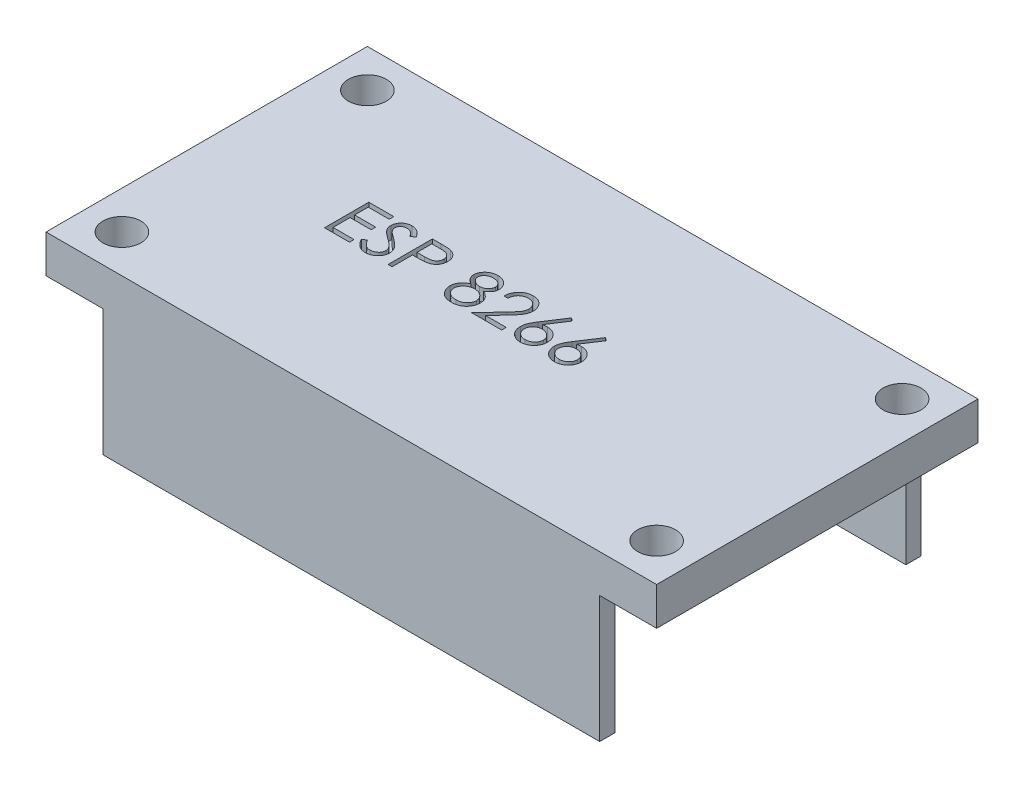
from build123d import *

# Parameters (mm, degrees)
SKETCH1_W           = 48.26
SKETCH1_H           = 25.4
BOSS_EXTRUDE1_DEPTH = 13
CUT_EXTRUDE1_DEPTH  = 10
CUT_EXTRUDE2_DEPTH  = 1
SKETCH4_R           = 1.5
CUT_EXTRUDE3_DEPTH  = 30


with BuildPart() as part:
    # Sketch1 → Boss-Extrude1 (new body)
    with BuildSketch(Plane(origin=(0, 0, 0), x_dir=(1, 0, 0), z_dir=(0, 1, 0))):
        with Locations((24.13, 12.7)):
            Rectangle(SKETCH1_W, SKETCH1_H)
    extrude(amount=BOSS_EXTRUDE1_DEPTH)

    # Sketch2 → Cut-Extrude1 (cut)
    with BuildSketch(Plane.XZ):
        Polygon((0, -1.2), (0, -24.2), (0, -25.4), (4.5, -25.4), (4.5, -24.2), (43.76, -24.2), (43.76, -25.4), (48.26, -25.4), (48.26, -24.2), (48.26, -1.2), (48.26, 0), (43.76, 0), (43.76, -1.2), (4.5, -1.2), (4.5, 0), (0, 0), align=None)
    extrude(amount=-CUT_EXTRUDE1_DEPTH, mode=Mode.SUBTRACT)

    # Sketch3 → Cut-Extrude2 (cut)
    with BuildSketch(Plane(origin=(0, 13, 0), x_dir=(1, 0, 0), z_dir=(0, 1, 0))):
        Polygon((10.717978937, 14.794873537), (12.692337911, 14.794873537), (12.692337911, 14.435899178), (11.032081501, 14.435899178), (11.032081501, 13.358976101), (12.692337911, 13.358976101), (12.692337911, 13.000001742), (11.032081501, 13.000001742), (11.032081501, 11.653847896), (12.692337911, 11.653847896), (12.692337911, 11.294873537), (10.717978937, 11.294873537), align=None)
        with BuildLine():
            Line((12.96156868, 11.970053825), (13.257442078, 12.147437639))
            add(Edge.make_bspline(
                [(13.257442078, 12.147437639), (13.284960315, 12.101373254), (13.337684196, 12.01311567), (13.425635555, 11.89385763), (13.516768466, 11.792495473), (13.6117578, 11.709618866), (13.710023748, 11.644369979), (13.812207801, 11.598167747), (13.917965612, 11.569351772), (13.989939434, 11.565851685), (14.025871565, 11.564104306)],
                knots=[0, 0, 0, 0, 0.000160901, 0.00030828, 0.000443778, 0.00056903, 0.000685513, 0.000796284, 0.00090427, 0.001011928, 0.001011928, 0.001011928, 0.001011928], degree=3))
            add(Edge.make_bspline(
                [(14.025871565, 11.564104306), (14.056558426, 11.564958978), (14.117395199, 11.566653369), (14.206957442, 11.582934171), (14.293939244, 11.6079463), (14.376547882, 11.643767231), (14.453643496, 11.687105717), (14.521250191, 11.739451894), (14.579696305, 11.7980581), (14.627505419, 11.863440755), (14.664185454, 11.933757903), (14.692377523, 12.005933855), (14.708022596, 12.081102423), (14.71037935, 12.131712886), (14.71156868, 12.157253344)],
                knots=[0, 0, 0, 0, 9.1978e-05, 0.000182347, 0.000272202, 0.000362975, 0.000451852, 0.000536835, 0.000618639, 0.000699414, 0.000778765, 0.000855983, 0.0009312, 0.001007828, 0.001007828, 0.001007828, 0.001007828], degree=3))
            add(Edge.make_bspline(
                [(14.71156868, 12.157253344), (14.71009437, 12.186394194), (14.707097311, 12.245633283), (14.681765831, 12.333032936), (14.641916585, 12.419525506), (14.605153941, 12.473026772), (14.586067879, 12.500803024)],
                knots=[0, 0, 0, 0, 8.7281e-05, 0.000177429, 0.000270909, 0.000371844, 0.000371844, 0.000371844, 0.000371844], degree=3))
            add(Edge.make_bspline(
                [(14.586067879, 12.500803024), (14.570397265, 12.520849847), (14.537498771, 12.562935646), (14.480941258, 12.625580881), (14.414575144, 12.6901993), (14.340671589, 12.759258357), (14.2565385, 12.829546154), (14.164810986, 12.904414432), (14.063147127, 12.981016009), (13.99184763, 13.032388575), (13.955058264, 13.058895972)],
                knots=[0, 0, 0, 0, 7.6319e-05, 0.000160223, 0.000252933, 0.000354147, 0.000463581, 0.000581729, 0.000709336, 0.000845369, 0.000845369, 0.000845369, 0.000845369], degree=3))
            add(Edge.make_bspline(
                [(13.955058264, 13.058895972), (13.918234268, 13.08512456), (13.847829591, 13.135271622), (13.749371009, 13.209695906), (13.661326546, 13.277739776), (13.584087529, 13.340043788), (13.517687932, 13.396616393), (13.461604521, 13.446914332), (13.417265964, 13.492297893), (13.392610383, 13.521739234), (13.381540636, 13.534957671)],
                knots=[0, 0, 0, 0, 0.000135623, 0.000259301, 0.000370234, 0.000469439, 0.00055697, 0.000631911, 0.000695377, 0.00074709, 0.00074709, 0.00074709, 0.00074709], degree=3))
            add(Edge.make_bspline(
                [(13.381540636, 13.534957671), (13.36606809, 13.555558708), (13.335639254, 13.596073412), (13.295473248, 13.65939827), (13.261334085, 13.724221535), (13.234571753, 13.7907174), (13.212035534, 13.857952328), (13.196877604, 13.926803574), (13.187386207, 13.996962193), (13.18641422, 14.044175693), (13.185927655, 14.067810235)],
                knots=[0, 0, 0, 0, 7.727e-05, 0.000151962, 0.000224716, 0.000296717, 0.00036678, 0.0004372, 0.000507902, 0.000578771, 0.000578771, 0.000578771, 0.000578771], degree=3))
            add(Edge.make_bspline(
                [(13.185927655, 14.067810235), (13.187232864, 14.10484001), (13.189815384, 14.178108074), (13.211655901, 14.285138904), (13.246128795, 14.387325321), (13.294423683, 14.483655655), (13.356681036, 14.571621636), (13.42872701, 14.652235123), (13.514538496, 14.720003705), (13.608691119, 14.779215763), (13.711747491, 14.825561689), (13.819738395, 14.860522669), (13.932835467, 14.880331927), (14.009438601, 14.883174691), (14.048307462, 14.884617126)],
                knots=[0, 0, 0, 0, 0.000110999, 0.000219625, 0.000326272, 0.00043382, 0.000541574, 0.000648775, 0.000756959, 0.000868438, 0.000981703, 0.00109501, 0.001208203, 0.0013248, 0.0013248, 0.0013248, 0.0013248], degree=3))
            add(Edge.make_bspline(
                [(14.048307462, 14.884617126), (14.089551563, 14.883194575), (14.171572914, 14.880365574), (14.29222213, 14.855768042), (14.408382846, 14.815067371), (14.501826111, 14.768878713), (14.574958873, 14.722747297), (14.630731605, 14.680727473), (14.687249056, 14.632352364), (14.744967111, 14.577493118), (14.80290777, 14.515646367), (14.861931223, 14.447235678), (14.922175492, 14.372679122), (14.960931352, 14.319454621), (14.98079945, 14.29216921)],
                knots=[0, 0, 0, 0, 0.000123638, 0.000245877, 0.000367608, 0.000492088, 0.000557638, 0.000626769, 0.000701372, 0.00078072, 0.000865532, 0.000955497, 0.001051745, 0.001152989, 0.001152989, 0.001152989, 0.001152989], degree=3))
            Line((14.98079945, 14.29216921), (14.696845123, 14.076924819))
            add(Edge.make_bspline(
                [(14.696845123, 14.076924819), (14.67969919, 14.099013509), (14.646680133, 14.141551162), (14.596550646, 14.201122478), (14.549301998, 14.255538957), (14.502751599, 14.302804085), (14.459357967, 14.345506219), (14.417240925, 14.382065976), (14.377006574, 14.412841571), (14.326289663, 14.445685131), (14.262571945, 14.478241635), (14.182587408, 14.505790713), (14.099001133, 14.522345775), (14.042071502, 14.524534662), (14.013251373, 14.525642767)],
                knots=[0, 0, 0, 0, 8.3877e-05, 0.000161528, 0.000233552, 0.000299993, 0.000360485, 0.000416152, 0.000467195, 0.000512312, 0.000597287, 0.000681099, 0.000765389, 0.000851809, 0.000851809, 0.000851809, 0.000851809], degree=3))
            add(Edge.make_bspline(
                [(14.013251373, 14.525642767), (13.97709485, 14.524431067), (13.907370403, 14.522094418), (13.808380167, 14.496574433), (13.719286242, 14.456392573), (13.642733677, 14.400077595), (13.5789967, 14.333356602), (13.532891241, 14.256577747), (13.505141076, 14.171795344), (13.501754797, 14.112653688), (13.500030219, 14.082533793)],
                knots=[0, 0, 0, 0, 0.000108248, 0.000208746, 0.00030443, 0.000399793, 0.000492054, 0.00057947, 0.000666386, 0.000756591, 0.000756591, 0.000756591, 0.000756591], degree=3))
            add(Edge.make_bspline(
                [(13.500030219, 14.082533793), (13.500423345, 14.063782314), (13.501210242, 14.026248695), (13.512185039, 13.970797273), (13.526284368, 13.915485934), (13.548627, 13.860563351), (13.579472304, 13.805068992), (13.61997748, 13.748047254), (13.670990792, 13.688995546), (13.710067804, 13.650588172), (13.730699289, 13.630310235)],
                knots=[0, 0, 0, 0, 5.616e-05, 0.000112411, 0.000169046, 0.000227244, 0.000289691, 0.000359134, 0.000436702, 0.000523463, 0.000523463, 0.000523463, 0.000523463], degree=3))
            add(Edge.make_bspline(
                [(13.730699289, 13.630310235), (13.738360662, 13.623473209), (13.756562329, 13.607230001), (13.789838255, 13.580637721), (13.833781053, 13.547834948), (13.887243254, 13.507247632), (13.951210616, 13.46016617), (14.025690172, 13.407192557), (14.109851705, 13.346607098), (14.169573621, 13.304249558), (14.201152014, 13.281852703)],
                knots=[0, 0, 0, 0, 3.0802e-05, 7.3177e-05, 0.000127725, 0.000195314, 0.000274544, 0.000365991, 0.000469501, 0.000585644, 0.000585644, 0.000585644, 0.000585644], degree=3))
            add(Edge.make_bspline(
                [(14.201152014, 13.281852703), (14.239137927, 13.254211344), (14.312692383, 13.200687682), (14.417349963, 13.120272002), (14.512243771, 13.041624233), (14.597706975, 12.965246626), (14.674583883, 12.891718533), (14.742021604, 12.820155353), (14.800707284, 12.75106978), (14.863886503, 12.662497205), (14.928444322, 12.55371612), (14.98388583, 12.420437882), (15.018844177, 12.286641561), (15.023415693, 12.196714725), (15.025671244, 12.152345492)],
                knots=[0, 0, 0, 0, 0.000140932, 0.000272896, 0.000395881, 0.000510584, 0.000616697, 0.000714904, 0.000805482, 0.000888372, 0.001041088, 0.001183793, 0.001320341, 0.001453327, 0.001453327, 0.001453327, 0.001453327], degree=3))
            add(Edge.make_bspline(
                [(15.025671244, 12.152345492), (15.025014106, 12.120967127), (15.023712591, 12.058819743), (15.008751678, 11.967564666), (14.986832012, 11.878933797), (14.953794778, 11.794022684), (14.91347162, 11.711277921), (14.862305372, 11.632870021), (14.802997688, 11.557063622), (14.734963923, 11.485880131), (14.66051802, 11.420533935), (14.581834326, 11.362404874), (14.498784053, 11.31393655), (14.411817736, 11.274385708), (14.320915399, 11.243452191), (14.226107615, 11.221039321), (14.127238104, 11.207283611), (14.060037623, 11.205855849), (14.025871565, 11.205129947)],
                knots=[0, 0, 0, 0, 9.4044e-05, 0.000186263, 0.000276729, 0.000367488, 0.000459046, 0.000552398, 0.000647774, 0.000747454, 0.000847311, 0.000944634, 0.001040472, 0.001135227, 0.001230788, 0.001328063, 0.00142712, 0.00152957, 0.00152957, 0.00152957, 0.00152957], degree=3))
            add(Edge.make_bspline(
                [(14.025871565, 11.205129947), (13.999436222, 11.205641128), (13.946898462, 11.206657054), (13.86918898, 11.215638334), (13.793049391, 11.228345438), (13.719435109, 11.248519508), (13.647397697, 11.272996485), (13.577250463, 11.303134817), (13.508959409, 11.339252019), (13.442141826, 11.380547044), (13.376967651, 11.428604788), (13.314048183, 11.484578285), (13.251318998, 11.54692379), (13.190631602, 11.617334353), (13.130758457, 11.694672436), (13.072880048, 11.779661619), (13.01579833, 11.871838973), (12.979982862, 11.936704059), (12.96156868, 11.970053825)],
                knots=[0, 0, 0, 0, 7.9276e-05, 0.000157554, 0.000234438, 0.000310629, 0.000386236, 0.000462555, 0.000539392, 0.000617798, 0.000698008, 0.000781971, 0.000870217, 0.00096315, 0.001060616, 0.001163492, 0.001271478, 0.00138575, 0.00138575, 0.00138575, 0.00138575], degree=3))
        make_face()
        with BuildLine():
            Line((15.743619962, 14.794873537), (16.4300182, 14.794873537))
            add(Edge.make_bspline(
                [(16.4300182, 14.794873537), (16.477229106, 14.79482164), (16.567687299, 14.794722205), (16.697402354, 14.791707459), (16.815212086, 14.787680767), (16.920862467, 14.782098874), (17.014678565, 14.775502283), (17.096235864, 14.766250244), (17.166175421, 14.756589949), (17.20808187, 14.746768542), (17.22719368, 14.742289402)],
                knots=[0, 0, 0, 0, 0.000141628, 0.000271366, 0.00038923, 0.000495248, 0.00058876, 0.000671296, 0.000741499, 0.00080036, 0.00080036, 0.00080036, 0.00080036], degree=3))
            add(Edge.make_bspline(
                [(17.22719368, 14.742289402), (17.251387214, 14.735667452), (17.299204191, 14.72257959), (17.368105234, 14.696365867), (17.43365908, 14.665283702), (17.496090638, 14.629859762), (17.554632721, 14.588574198), (17.610158762, 14.54310058), (17.662178743, 14.492389011), (17.710400135, 14.437008272), (17.754684932, 14.377888062), (17.792814615, 14.314145832), (17.824741842, 14.246854528), (17.852125113, 14.176060957), (17.871833568, 14.101170634), (17.886680468, 14.022703921), (17.896104095, 13.940669231), (17.897006657, 13.884609364), (17.897466116, 13.856071453)],
                knots=[0, 0, 0, 0, 7.5216e-05, 0.00014866, 0.000220794, 0.000292713, 0.000363707, 0.000435434, 0.000507823, 0.000581364, 0.000655543, 0.000729131, 0.000803767, 0.000878771, 0.000956497, 0.001035702, 0.001118238, 0.001203821, 0.001203821, 0.001203821, 0.001203821], degree=3))
            add(Edge.make_bspline(
                [(17.897466116, 13.856071453), (17.897044692, 13.827293676), (17.896220146, 13.770988013), (17.88632386, 13.688615224), (17.872993669, 13.609896834), (17.852496616, 13.535007384), (17.825650943, 13.464391613), (17.79415889, 13.396970381), (17.75617536, 13.333890709), (17.71253053, 13.274923592), (17.663978936, 13.220013679), (17.610725998, 13.169558885), (17.552986705, 13.123854547), (17.490944557, 13.082798203), (17.423994708, 13.047341923), (17.353152555, 13.015584618), (17.277802338, 12.988913558), (17.225659824, 12.974883496), (17.199148809, 12.967750139)],
                knots=[0, 0, 0, 0, 8.6284e-05, 0.00016882, 0.000248587, 0.000325638, 0.000401297, 0.000474998, 0.000548586, 0.000621785, 0.0006948, 0.0007682, 0.000841564, 0.000915458, 0.000991056, 0.00106858, 0.00114819, 0.001230532, 0.001230532, 0.001230532, 0.001230532], degree=3))
            add(Edge.make_bspline(
                [(17.199148809, 12.967750139), (17.177221475, 12.963087158), (17.129166447, 12.952867964), (17.050023725, 12.941459507), (16.957878339, 12.931721906), (16.852856059, 12.924420769), (16.735051154, 12.9181704), (16.604399897, 12.913202306), (16.46064582, 12.910472453), (16.360374576, 12.91033166), (16.308023007, 12.910258152)],
                knots=[0, 0, 0, 0, 6.7238e-05, 0.000147357, 0.000239727, 0.000345177, 0.000463135, 0.000593636, 0.000737393, 0.000894446, 0.000894446, 0.000894446, 0.000894446], degree=3))
            Line((16.308023007, 12.910258152), (16.057722527, 12.910258152))
            Line((16.057722527, 12.910258152), (16.057722527, 11.294873537))
            Line((16.057722527, 11.294873537), (15.743619962, 11.294873537))
            Line((15.743619962, 11.294873537), (15.743619962, 14.794873537))
        make_face()
        with BuildLine():
            Line((16.057722527, 14.435899178), (16.057722527, 13.269232511))
            Line((16.057722527, 13.269232511), (16.670502975, 13.261520171))
            add(Edge.make_bspline(
                [(16.670502975, 13.261520171), (16.700422901, 13.261504708), (16.758182701, 13.261474855), (16.841618924, 13.265460079), (16.919028212, 13.270060612), (16.990172787, 13.276796535), (17.055084721, 13.286317793), (17.11387225, 13.29592953), (17.166079533, 13.309834893), (17.227178735, 13.328557962), (17.295262082, 13.360490578), (17.369329631, 13.406840468), (17.432100217, 13.465921176), (17.486418514, 13.532349007), (17.529524392, 13.606248137), (17.561080384, 13.685317074), (17.579621542, 13.768744923), (17.582107735, 13.825833062), (17.583363552, 13.85466921)],
                knots=[0, 0, 0, 0, 8.9746e-05, 0.000173253, 0.000250533, 0.00032239, 0.000387534, 0.00044736, 0.000500926, 0.000549486, 0.000638903, 0.000725641, 0.000810488, 0.000896226, 0.000982324, 0.00106604, 0.001150757, 0.001237226, 0.001237226, 0.001237226, 0.001237226], degree=3))
            add(Edge.make_bspline(
                [(17.583363552, 13.85466921), (17.582100906, 13.882807723), (17.579590921, 13.938743605), (17.560935058, 14.020722366), (17.529585744, 14.09895807), (17.486129149, 14.171931156), (17.433388019, 14.23811996), (17.372088676, 14.295617087), (17.302375415, 14.341838789), (17.237527184, 14.371672071), (17.179925998, 14.389887346), (17.129894038, 14.402632187), (17.073403363, 14.412807793), (17.010435584, 14.421047296), (16.94147875, 14.428100757), (16.865940435, 14.432886734), (16.784106792, 14.435688191), (16.727296221, 14.435827146), (16.697846725, 14.435899178)],
                knots=[0, 0, 0, 0, 8.4371e-05, 0.000167719, 0.000250783, 0.000336277, 0.000421575, 0.000503926, 0.000587348, 0.000671427, 0.000717102, 0.000768457, 0.000826213, 0.000889178, 0.000958942, 0.001034123, 0.001116202, 0.001204546, 0.001204546, 0.001204546, 0.001204546], degree=3))
            Line((16.697846725, 14.435899178), (16.057722527, 14.435899178))
        make_face(mode=Mode.SUBTRACT)
        with BuildLine():
            add(Edge.make_bspline(
                [(21.349088712, 13.244693248), (21.37773726, 13.229755292), (21.433611494, 13.200621289), (21.513188702, 13.153710462), (21.585913704, 13.104269497), (21.653804265, 13.054633637), (21.715667616, 13.002901986), (21.770812029, 12.94886883), (21.820599649, 12.893882884), (21.864026433, 12.837013044), (21.90222327, 12.778410395), (21.935235405, 12.717921122), (21.963452608, 12.655677788), (21.985815546, 12.591000958), (22.004237338, 12.524840697), (22.016912943, 12.456342715), (22.023729861, 12.385958374), (22.025018674, 12.338390072), (22.025671244, 12.314304626)],
                knots=[0, 0, 0, 0, 9.692e-05, 0.000189026, 0.000276921, 0.000360637, 0.000441251, 0.000518597, 0.000592078, 0.000663595, 0.000733021, 0.000801734, 0.000870147, 0.000937778, 0.001006834, 0.001076004, 0.001146466, 0.001218736, 0.001218736, 0.001218736, 0.001218736], degree=3))
            add(Edge.make_bspline(
                [(22.025671244, 12.314304626), (22.024899824, 12.280606894), (22.023372893, 12.213906437), (22.010072909, 12.115460325), (21.990159931, 12.019848543), (21.961080418, 11.927092053), (21.923367028, 11.837702679), (21.876890192, 11.751603906), (21.824278986, 11.667384597), (21.782026747, 11.615565195), (21.760647206, 11.58934469)],
                knots=[0, 0, 0, 0, 0.000101049, 0.000200014, 0.00029751, 0.000393751, 0.000491154, 0.000588073, 0.000687071, 0.000788472, 0.000788472, 0.000788472, 0.000788472], degree=3))
            add(Edge.make_bspline(
                [(21.760647206, 11.58934469), (21.732810732, 11.558750916), (21.677481766, 11.497941424), (21.582698839, 11.418990614), (21.478676955, 11.35264122), (21.365818622, 11.298569325), (21.244425521, 11.256483466), (21.114523516, 11.226240948), (20.975859363, 11.208918519), (20.880553892, 11.206414529), (20.831660828, 11.205129947)],
                knots=[0, 0, 0, 0, 0.000123978, 0.000246423, 0.000368759, 0.000493253, 0.000620972, 0.000753455, 0.000892683, 0.001039354, 0.001039354, 0.001039354, 0.001039354], degree=3))
            add(Edge.make_bspline(
                [(20.831660828, 11.205129947), (20.784647439, 11.206282425), (20.69316416, 11.20852503), (20.560006283, 11.223719461), (20.435883213, 11.250347328), (20.320073245, 11.286791937), (20.213274551, 11.334202166), (20.11579145, 11.393210574), (20.026217478, 11.461442017), (19.947271004, 11.540856095), (19.87718256, 11.625913967), (19.815614507, 11.713665577), (19.764440429, 11.804118934), (19.721113333, 11.895925302), (19.687945311, 11.990371456), (19.6649731, 12.086971469), (19.650383786, 12.185556612), (19.648442651, 12.252088265), (19.647466116, 12.285558633)],
                knots=[0, 0, 0, 0, 0.000141037, 0.000274444, 0.00040137, 0.000521327, 0.000638076, 0.000750983, 0.00086247, 0.000975011, 0.001086056, 0.001192834, 0.001296147, 0.001397463, 0.001497025, 0.001595826, 0.001694979, 0.00179536, 0.00179536, 0.00179536, 0.00179536], degree=3))
            add(Edge.make_bspline(
                [(19.647466116, 12.285558633), (19.648043997, 12.310117825), (19.649186094, 12.358655457), (19.657090942, 12.430364785), (19.669799404, 12.50016092), (19.687058861, 12.568301663), (19.710449887, 12.634290936), (19.73869202, 12.69844141), (19.771623973, 12.760825509), (19.809705138, 12.82178439), (19.854007162, 12.880463902), (19.904170811, 12.937859896), (19.96119868, 12.993081764), (20.024456339, 13.046804189), (20.093220878, 13.099980162), (20.169278409, 13.149735891), (20.250612677, 13.199593856), (20.308418082, 13.229402181), (20.338071084, 13.244693248)],
                knots=[0, 0, 0, 0, 7.3671e-05, 0.0001456, 0.000216149, 0.000286381, 0.000356229, 0.000425923, 0.00049649, 0.000567687, 0.000641305, 0.000716824, 0.000796154, 0.000879197, 0.00096572, 0.001056725, 0.001151716, 0.001251771, 0.001251771, 0.001251771, 0.001251771], degree=3))
            add(Edge.make_bspline(
                [(20.338071084, 13.244693248), (20.29747971, 13.266828017), (20.218883447, 13.309687124), (20.114814006, 13.38843393), (20.025423382, 13.473721745), (19.953168664, 13.56735154), (19.896296436, 13.666398414), (19.857277832, 13.770242667), (19.830881348, 13.87695878), (19.828266521, 13.949864977), (19.826953296, 13.986480107)],
                knots=[0, 0, 0, 0, 0.000138535, 0.000268243, 0.000390218, 0.00050816, 0.000621822, 0.000731457, 0.000840134, 0.00094978, 0.00094978, 0.00094978, 0.00094978], degree=3))
            add(Edge.make_bspline(
                [(19.826953296, 13.986480107), (19.82858872, 14.023777665), (19.831876208, 14.098752262), (19.858459528, 14.210358386), (19.901779595, 14.319974951), (19.960700592, 14.427070664), (20.034087808, 14.528020878), (20.122134354, 14.618561824), (20.22273765, 14.697873307), (20.335395517, 14.76444948), (20.456631753, 14.818633139), (20.584547477, 14.856011561), (20.71691397, 14.880447678), (20.80701169, 14.883214333), (20.852694482, 14.884617126)],
                knots=[0, 0, 0, 0, 0.000111795, 0.000224728, 0.000342168, 0.000464543, 0.000590474, 0.000715423, 0.000842224, 0.000973648, 0.001107055, 0.001239485, 0.001372621, 0.001509557, 0.001509557, 0.001509557, 0.001509557], degree=3))
            add(Edge.make_bspline(
                [(20.852694482, 14.884617126), (20.897198297, 14.883170783), (20.98495475, 14.880318759), (21.113949377, 14.856531881), (21.237374255, 14.816802362), (21.354803754, 14.762905138), (21.464135621, 14.696518197), (21.56073793, 14.616117323), (21.646070512, 14.525975773), (21.716654907, 14.425056169), (21.774817796, 14.318371976), (21.815318697, 14.206749455), (21.841270671, 14.092600396), (21.844544035, 14.015362392), (21.846184065, 13.976664402)],
                knots=[0, 0, 0, 0, 0.000133436, 0.000263121, 0.000391946, 0.000521517, 0.000649943, 0.000774455, 0.000897469, 0.001021193, 0.0011429, 0.001260905, 0.001376422, 0.001492413, 0.001492413, 0.001492413, 0.001492413], degree=3))
            add(Edge.make_bspline(
                [(21.846184065, 13.976664402), (21.844749504, 13.938687738), (21.841932109, 13.864103729), (21.818232169, 13.755377208), (21.778318856, 13.653555169), (21.723824693, 13.557482217), (21.652799205, 13.46890072), (21.566190472, 13.38668425), (21.464688994, 13.310157421), (21.388428108, 13.266971057), (21.349088712, 13.244693248)],
                knots=[0, 0, 0, 0, 0.000113843, 0.000223582, 0.000331909, 0.000440874, 0.000553657, 0.00067118, 0.000798364, 0.000933876, 0.000933876, 0.000933876, 0.000933876], degree=3))
        make_face()
        with BuildLine():
            add(Edge.make_bspline(
                [(20.835166437, 14.525642767), (20.810615631, 14.524991327), (20.76258352, 14.523716824), (20.692154849, 14.517058187), (20.625182481, 14.50410497), (20.560966681, 14.486866259), (20.500387868, 14.463578271), (20.442623314, 14.436183262), (20.388656124, 14.402877196), (20.337834821, 14.365515998), (20.292084047, 14.324423092), (20.251479495, 14.281609373), (20.217751381, 14.236233981), (20.189110271, 14.189425621), (20.168328754, 14.139795045), (20.15276445, 14.088863869), (20.142243058, 14.035988485), (20.141454668, 13.999851974), (20.14105586, 13.981572255)],
                knots=[0, 0, 0, 0, 7.3671e-05, 0.000144133, 0.000211925, 0.000278091, 0.000343329, 0.00040636, 0.000469609, 0.000533272, 0.00059534, 0.000653874, 0.000709964, 0.000764674, 0.00081807, 0.000870854, 0.000924347, 0.000979106, 0.000979106, 0.000979106, 0.000979106], degree=3))
            add(Edge.make_bspline(
                [(20.14105586, 13.981572255), (20.141743227, 13.963291745), (20.143101563, 13.927166832), (20.153606691, 13.873820966), (20.169263545, 13.821399329), (20.193914207, 13.771148418), (20.223480565, 13.721325059), (20.259972041, 13.673174473), (20.303461069, 13.626529088), (20.352488509, 13.581785647), (20.405900047, 13.539886884), (20.46248409, 13.503513702), (20.521530482, 13.473079592), (20.582432551, 13.447750187), (20.645810998, 13.42806025), (20.711277472, 13.414091603), (20.778842974, 13.405409607), (20.824623555, 13.404372585), (20.847786629, 13.403847896)],
                knots=[0, 0, 0, 0, 5.48e-05, 0.000108292, 0.000162623, 0.00021845, 0.000275685, 0.000336262, 0.000399273, 0.000466763, 0.000535204, 0.00060269, 0.000668229, 0.000734243, 0.000800327, 0.000867022, 0.000934854, 0.001004321, 0.001004321, 0.001004321, 0.001004321], degree=3))
            add(Edge.make_bspline(
                [(20.847786629, 13.403847896), (20.877536733, 13.404720763), (20.936743101, 13.406457876), (21.024022432, 13.42260905), (21.108885077, 13.448014967), (21.190423981, 13.482774933), (21.266528566, 13.526402793), (21.334368634, 13.578635811), (21.393365527, 13.638267909), (21.442906137, 13.704370744), (21.481315984, 13.774722333), (21.511217792, 13.845322625), (21.528679007, 13.916924856), (21.530956574, 13.96489182), (21.532081501, 13.988583472)],
                knots=[0, 0, 0, 0, 8.9178e-05, 0.000177474, 0.000265314, 0.000354521, 0.00044279, 0.000527774, 0.000610569, 0.000693722, 0.000774691, 0.000850468, 0.000923253, 0.000994288, 0.000994288, 0.000994288, 0.000994288], degree=3))
            add(Edge.make_bspline(
                [(21.532081501, 13.988583472), (21.531549603, 14.005211508), (21.530493863, 14.038215776), (21.521793807, 14.086954142), (21.507417974, 14.134583725), (21.487954894, 14.181497996), (21.462345099, 14.227038728), (21.431980912, 14.271921816), (21.39509641, 14.31513758), (21.353699977, 14.357693128), (21.306754568, 14.397077152), (21.254350656, 14.431711862), (21.196756905, 14.461124219), (21.133971956, 14.485012974), (21.066227031, 14.502955323), (20.993834157, 14.516391671), (20.91618971, 14.523964782), (20.862759959, 14.525071308), (20.835166437, 14.525642767)],
                knots=[0, 0, 0, 0, 4.9859e-05, 9.8962e-05, 0.000147986, 0.000198898, 0.000250994, 0.000304472, 0.000361207, 0.000421197, 0.00048242, 0.000544646, 0.00060924, 0.000676039, 0.000745771, 0.000819205, 0.000896713, 0.000979493, 0.000979493, 0.000979493, 0.000979493], degree=3))
        make_face(mode=Mode.SUBTRACT)
        with BuildLine():
            add(Edge.make_bspline(
                [(20.855498969, 13.044873537), (20.824373183, 13.044319895), (20.763311987, 13.043233786), (20.673855059, 13.031144286), (20.588001893, 13.014314892), (20.506041957, 12.988784054), (20.42800986, 12.955587564), (20.353483177, 12.915653024), (20.283032048, 12.868447581), (20.217629321, 12.814570965), (20.157905992, 12.756511511), (20.105507692, 12.695049376), (20.061010172, 12.631326843), (20.025176921, 12.564534614), (19.995765189, 12.496087003), (19.976451311, 12.424279408), (19.9640696, 12.350492295), (19.962406968, 12.300332196), (19.96156868, 12.275041806)],
                knots=[0, 0, 0, 0, 9.3315e-05, 0.000183061, 0.000270376, 0.000355532, 0.000440046, 0.000524429, 0.000608823, 0.000694017, 0.000778303, 0.000858382, 0.000935982, 0.001010962, 0.001085443, 0.001158927, 0.001233504, 0.001309342, 0.001309342, 0.001309342, 0.001309342], degree=3))
            add(Edge.make_bspline(
                [(19.96156868, 12.275041806), (19.962931939, 12.2436109), (19.965636613, 12.181252716), (19.987093252, 12.089089645), (20.021528787, 11.99986859), (20.069554003, 11.914316637), (20.129021576, 11.834366531), (20.202148044, 11.764677756), (20.284388881, 11.702756277), (20.378526735, 11.652675744), (20.481355201, 11.612680889), (20.59284693, 11.585124926), (20.711401849, 11.566883476), (20.793261441, 11.565045295), (20.835166437, 11.564104306)],
                knots=[0, 0, 0, 0, 9.4212e-05, 0.000186914, 0.000282354, 0.00038028, 0.000480401, 0.000580061, 0.000682286, 0.000788322, 0.000898864, 0.001012456, 0.001132235, 0.001257861, 0.001257861, 0.001257861, 0.001257861], degree=3))
            add(Edge.make_bspline(
                [(20.835166437, 11.564104306), (20.867916805, 11.564733114), (20.931725024, 11.565958235), (21.024810973, 11.576772529), (21.112655521, 11.593922154), (21.19508832, 11.618865699), (21.273032159, 11.649315676), (21.345165513, 11.688487758), (21.413344041, 11.733040081), (21.474208163, 11.785898237), (21.529641372, 11.842377732), (21.577974665, 11.902167775), (21.619932216, 11.963643407), (21.652863171, 12.028193892), (21.679189425, 12.094580807), (21.69811298, 12.163416318), (21.709789195, 12.234911551), (21.710970091, 12.283410622), (21.71156868, 12.30799453)],
                knots=[0, 0, 0, 0, 9.822e-05, 0.000191363, 0.000280739, 0.000366362, 0.000449427, 0.000531293, 0.000612187, 0.000693253, 0.000772583, 0.000849342, 0.000923624, 0.000995434, 0.001066261, 0.001137531, 0.001209227, 0.001282928, 0.001282928, 0.001282928, 0.001282928], degree=3))
            add(Edge.make_bspline(
                [(21.71156868, 12.30799453), (21.710662832, 12.331871871), (21.708876657, 12.378953815), (21.697539965, 12.448720342), (21.677624088, 12.516123156), (21.650296691, 12.581973162), (21.613915729, 12.644936113), (21.571070859, 12.706652284), (21.51937674, 12.765408729), (21.460964144, 12.821661825), (21.397305183, 12.873677562), (21.329638038, 12.919692), (21.258483576, 12.958444116), (21.183992365, 12.989960612), (21.10632981, 13.014748081), (21.025553031, 13.032064077), (20.941567456, 13.04296368), (20.884512585, 13.044229725), (20.855498969, 13.044873537)],
                knots=[0, 0, 0, 0, 7.1638e-05, 0.000141258, 0.00021137, 0.000282076, 0.000354604, 0.000429101, 0.000507127, 0.000588942, 0.000672164, 0.000753448, 0.00083408, 0.000914819, 0.000995752, 0.001078265, 0.001162358, 0.001249368, 0.001249368, 0.001249368, 0.001249368], degree=3))
        make_face(mode=Mode.SUBTRACT)
        with BuildLine():
            Line((22.788491757, 13.71795046), (22.474389193, 13.71795046))
            add(Edge.make_bspline(
                [(22.474389193, 13.71795046), (22.476436346, 13.759621347), (22.4804569, 13.841461862), (22.49928519, 13.960785768), (22.526226067, 14.074840567), (22.564317521, 14.182710481), (22.611623798, 14.285349288), (22.668353826, 14.382349304), (22.735547676, 14.473340493), (22.81175441, 14.557479336), (22.894523049, 14.634666907), (22.983828989, 14.70132215), (23.077674016, 14.757639821), (23.175773415, 14.804721063), (23.279233979, 14.840060909), (23.387116837, 14.866282548), (23.499895973, 14.882058894), (23.576735995, 14.88375468), (23.615815475, 14.884617126)],
                knots=[0, 0, 0, 0, 0.000125083, 0.00024566, 0.000361805, 0.000476223, 0.000588214, 0.000700404, 0.000812728, 0.00092691, 0.001040529, 0.001151727, 0.001260545, 0.001368429, 0.001477521, 0.001587884, 0.001701119, 0.00181831, 0.00181831, 0.00181831, 0.00181831], degree=3))
            add(Edge.make_bspline(
                [(23.615815475, 14.884617126), (23.654193549, 14.88371867), (23.729605094, 14.881953235), (23.839667108, 14.866792206), (23.944444403, 14.843046614), (24.043732169, 14.809731198), (24.136738234, 14.76494677), (24.224161279, 14.711149232), (24.307042089, 14.6489294), (24.381648873, 14.575675587), (24.450156952, 14.497473203), (24.509259207, 14.413985299), (24.559872371, 14.327756013), (24.602060051, 14.238127812), (24.63311619, 14.144256783), (24.656694398, 14.04750958), (24.670021811, 13.946884769), (24.672067235, 13.878778214), (24.673107142, 13.844152383)],
                knots=[0, 0, 0, 0, 0.000115089, 0.000226145, 0.000332614, 0.000437044, 0.000539592, 0.000641561, 0.000744629, 0.00084975, 0.000954621, 0.001056175, 0.001156101, 0.001254284, 0.001352726, 0.001452208, 0.001552655, 0.001656537, 0.001656537, 0.001656537, 0.001656537], degree=3))
            add(Edge.make_bspline(
                [(24.673107142, 13.844152383), (24.671420497, 13.795402574), (24.668076805, 13.698758445), (24.639221103, 13.556554088), (24.594639006, 13.418649028), (24.540565977, 13.307669976), (24.485945409, 13.218693083), (24.437765613, 13.144777442), (24.38011326, 13.065951025), (24.313515847, 12.981419916), (24.238978041, 12.890925547), (24.155963373, 12.79443078), (24.063837683, 12.692960475), (23.999179501, 12.623654662), (23.965675251, 12.587742126)],
                knots=[0, 0, 0, 0, 0.000146118, 0.000289672, 0.000433566, 0.000580006, 0.000658644, 0.000746735, 0.000844624, 0.000951498, 0.001069547, 0.001196319, 0.001333326, 0.00148067, 0.00148067, 0.00148067, 0.00148067], degree=3))
            Line((23.965675251, 12.587742126), (23.089974129, 11.653847896))
            Line((23.089974129, 11.653847896), (24.717978937, 11.653847896))
            Line((24.717978937, 11.653847896), (24.717978937, 11.294873537))
            Line((24.717978937, 11.294873537), (22.339773809, 11.294873537))
            Line((22.339773809, 11.294873537), (23.697145603, 12.743391165))
            add(Edge.make_bspline(
                [(23.697145603, 12.743391165), (23.73019349, 12.777889471), (23.793671717, 12.844153658), (23.883454294, 12.940896618), (23.964093283, 13.030646159), (24.036110675, 13.113232707), (24.097944181, 13.189864275), (24.152816413, 13.258058979), (24.196782004, 13.320813429), (24.244497399, 13.393554043), (24.290711381, 13.48236636), (24.330423737, 13.590900049), (24.354638585, 13.702627302), (24.357543421, 13.778129339), (24.359004578, 13.816107511)],
                knots=[0, 0, 0, 0, 0.000143319, 0.000275286, 0.00039593, 0.000505287, 0.000603949, 0.000691331, 0.000767782, 0.00083371, 0.000952247, 0.001067137, 0.001179618, 0.001293462, 0.001293462, 0.001293462, 0.001293462], degree=3))
            add(Edge.make_bspline(
                [(24.359004578, 13.816107511), (24.358368836, 13.839988909), (24.35711591, 13.88705456), (24.346058212, 13.956060319), (24.329347706, 14.022625133), (24.305402448, 14.086953752), (24.273795708, 14.148399404), (24.235322328, 14.207036884), (24.190932264, 14.263725849), (24.139580995, 14.316879147), (24.083169475, 14.365560353), (24.023575226, 14.408684438), (23.960525121, 14.444723549), (23.894284999, 14.474267046), (23.82503953, 14.497442427), (23.752654785, 14.513501007), (23.677330769, 14.523583491), (23.625897273, 14.524947663), (23.599689674, 14.525642767)],
                knots=[0, 0, 0, 0, 7.16e-05, 0.00014111, 0.00020913, 0.00027724, 0.000346538, 0.000415963, 0.000487357, 0.000562233, 0.000637292, 0.000710646, 0.000782564, 0.000854749, 0.000927915, 0.001001225, 0.001076884, 0.001155488, 0.001155488, 0.001155488, 0.001155488], degree=3))
            add(Edge.make_bspline(
                [(23.599689674, 14.525642767), (23.572318841, 14.524927735), (23.518567045, 14.52352353), (23.439648012, 14.513700866), (23.364362235, 14.496755025), (23.292520332, 14.473578351), (23.224000746, 14.444119802), (23.159136702, 14.407428058), (23.098073812, 14.363644564), (23.040697289, 14.314004008), (22.98783331, 14.258736407), (22.941386434, 14.197126444), (22.90080242, 14.130299028), (22.865393187, 14.058434478), (22.836637496, 13.980880698), (22.814664346, 13.897912993), (22.797277499, 13.809891612), (22.791468979, 13.749106527), (22.788491757, 13.71795046)],
                knots=[0, 0, 0, 0, 8.2106e-05, 0.000161243, 0.000238127, 0.000313291, 0.000387401, 0.000461495, 0.000536397, 0.000612445, 0.000688819, 0.000765383, 0.000843422, 0.000923066, 0.001005373, 0.001091093, 0.001180334, 0.001274175, 0.001274175, 0.001274175, 0.001274175], degree=3))
        make_face()
        with BuildLine():
            Line((26.647466116, 14.884617126), (26.890054257, 14.69461312))
            Line((26.890054257, 14.69461312), (25.96527461, 13.28045046))
            add(Edge.make_bspline(
                [(25.96527461, 13.28045046), (26.026844887, 13.29026432), (26.146944674, 13.309407365), (26.268510572, 13.312565311), (26.327754578, 13.314104306)],
                knots=[0, 0, 0, 0, 0.000186809, 0.000364392, 0.000364392, 0.000364392, 0.000364392], degree=3))
            add(Edge.make_bspline(
                [(26.327754578, 13.314104306), (26.363328864, 13.313162042), (26.433124173, 13.311313358), (26.535678607, 13.296703778), (26.634246, 13.273964048), (26.728606462, 13.240683071), (26.81887975, 13.198183039), (26.905582063, 13.147243538), (26.987084096, 13.085238031), (27.064435269, 13.015973027), (27.134662368, 12.939256056), (27.196838423, 12.857854715), (27.249065215, 12.771853835), (27.291439137, 12.681296969), (27.324344015, 12.58632371), (27.34833166, 12.48705557), (27.362511253, 12.383424099), (27.364436744, 12.312945923), (27.365414834, 12.277145171)],
                knots=[0, 0, 0, 0, 0.000106683, 0.000209309, 0.000310156, 0.000409717, 0.000508831, 0.000609114, 0.000710777, 0.000815526, 0.000920228, 0.001022313, 0.001122355, 0.001221469, 0.001321692, 0.001423384, 0.001527398, 0.001634782, 0.001634782, 0.001634782, 0.001634782], degree=3))
            add(Edge.make_bspline(
                [(27.365414834, 12.277145171), (27.363991729, 12.228165467), (27.361191396, 12.131785001), (27.3332876, 11.991408295), (27.289927955, 11.857675779), (27.227950427, 11.732722608), (27.150968044, 11.616720038), (27.057090451, 11.513934573), (26.949646963, 11.422264536), (26.828160164, 11.345607916), (26.6974172, 11.283004865), (26.560065203, 11.238039623), (26.417438057, 11.210356154), (26.320633448, 11.206885551), (26.271664834, 11.205129947)],
                knots=[0, 0, 0, 0, 0.000146776, 0.00028882, 0.000427614, 0.000567461, 0.000705914, 0.000843912, 0.000983689, 0.001128394, 0.001273595, 0.001417489, 0.001560911, 0.001707729, 0.001707729, 0.001707729, 0.001707729], degree=3))
            add(Edge.make_bspline(
                [(26.271664834, 11.205129947), (26.224568134, 11.206658153), (26.131277816, 11.209685261), (25.994045021, 11.236651198), (25.862182004, 11.280358301), (25.736612623, 11.34057258), (25.62029201, 11.416630463), (25.516226374, 11.508192742), (25.424934599, 11.613302207), (25.348959978, 11.731942554), (25.288701246, 11.859432512), (25.243511321, 11.992369668), (25.217115078, 12.13026965), (25.213426521, 12.223750789), (25.21156868, 12.270835075)],
                knots=[0, 0, 0, 0, 0.000141176, 0.000279646, 0.000417774, 0.000557008, 0.000696242, 0.000833365, 0.000971544, 0.001112541, 0.001254608, 0.001393623, 0.001532781, 0.001674001, 0.001674001, 0.001674001, 0.001674001], degree=3))
            add(Edge.make_bspline(
                [(25.21156868, 12.270835075), (25.212750125, 12.306879658), (25.21516241, 12.38047581), (25.232005801, 12.491939838), (25.259070595, 12.60599092), (25.289380842, 12.702745114), (25.321406452, 12.782006635), (25.348058991, 12.845910126), (25.381232988, 12.911671199), (25.416606369, 12.981544835), (25.457363238, 13.053730268), (25.501678887, 13.129433937), (25.550778538, 13.207451865), (25.585198701, 13.26039606), (25.602794642, 13.287461678)],
                knots=[0, 0, 0, 0, 0.000108118, 0.000220757, 0.000337422, 0.000459596, 0.000524434, 0.000593848, 0.000667222, 0.000745302, 0.000828791, 0.000915849, 0.00100845, 0.001105299, 0.001105299, 0.001105299, 0.001105299], degree=3))
            Line((25.602794642, 13.287461678), (26.647466116, 14.884617126))
        make_face()
        with BuildLine():
            add(Edge.make_bspline(
                [(26.261849129, 12.955129947), (26.235187737, 12.954341578), (26.182878305, 12.952794806), (26.106229346, 12.944059078), (26.033882985, 12.927505879), (25.96500812, 12.906098354), (25.900339906, 12.876934218), (25.839076662, 12.841987299), (25.781923493, 12.800117822), (25.729159392, 12.752851908), (25.681345169, 12.70105461), (25.640162622, 12.6455875), (25.604640589, 12.587772672), (25.575758673, 12.527130895), (25.553268624, 12.463684351), (25.537000366, 12.397725114), (25.527946616, 12.328810804), (25.526440385, 12.282078302), (25.525671244, 12.258214883)],
                knots=[0, 0, 0, 0, 8.0005e-05, 0.000156969, 0.000230963, 0.00030236, 0.000372979, 0.000443332, 0.000513592, 0.000585092, 0.000655554, 0.000724685, 0.000792022, 0.00085882, 0.000925791, 0.000993641, 0.001062258, 0.001133858, 0.001133858, 0.001133858, 0.001133858], degree=3))
            add(Edge.make_bspline(
                [(25.525671244, 12.258214883), (25.526297606, 12.234564903), (25.527525808, 12.188190813), (25.538678127, 12.119851634), (25.55571321, 12.054086725), (25.581053606, 11.991235126), (25.611280494, 11.930338808), (25.651185818, 11.873603523), (25.695402604, 11.817583453), (25.748256537, 11.766581981), (25.8049799, 11.719125357), (25.865581103, 11.677645104), (25.928741063, 11.64215893), (25.995312485, 11.614347833), (26.064350869, 11.591523546), (26.136431423, 11.575462067), (26.211604278, 11.566381541), (26.262526216, 11.564873347), (26.288491757, 11.564104306)],
                knots=[0, 0, 0, 0, 7.09e-05, 0.000139024, 0.000207221, 0.000274272, 0.000342002, 0.000410648, 0.000481932, 0.000555803, 0.000630491, 0.000703613, 0.000775798, 0.000847422, 0.000919703, 0.000993697, 0.001068572, 0.001146476, 0.001146476, 0.001146476, 0.001146476], degree=3))
            add(Edge.make_bspline(
                [(26.288491757, 11.564104306), (26.314457256, 11.564873407), (26.36537911, 11.566381719), (26.440552571, 11.575461388), (26.512630889, 11.591526036), (26.581677398, 11.614338806), (26.648218829, 11.642192416), (26.71132355, 11.677424335), (26.771351644, 11.719380453), (26.828112244, 11.766500881), (26.880746182, 11.817873733), (26.926023461, 11.873103456), (26.964706694, 11.930797351), (26.996140881, 11.990995241), (27.021202172, 12.054124729), (27.03832364, 12.119841453), (27.049452929, 12.188193479), (27.050684295, 12.234565803), (27.05131227, 12.258214883)],
                knots=[0, 0, 0, 0, 7.7903e-05, 0.000152779, 0.000226773, 0.000299053, 0.000370678, 0.000442863, 0.000515408, 0.000590096, 0.000663967, 0.000735694, 0.000803948, 0.000872001, 0.000939052, 0.001007249, 0.001075373, 0.001146273, 0.001146273, 0.001146273, 0.001146273], degree=3))
            add(Edge.make_bspline(
                [(27.05131227, 12.258214883), (27.050761976, 12.282109433), (27.049681929, 12.329006663), (27.03746599, 12.397694297), (27.020523579, 12.464019445), (26.994940687, 12.527565611), (26.961703617, 12.588080716), (26.921222236, 12.645875487), (26.874381721, 12.701373399), (26.820315142, 12.752984671), (26.761459537, 12.799826405), (26.699278409, 12.842144483), (26.633384767, 12.87660892), (26.564967508, 12.90619755), (26.493202566, 12.927166543), (26.418873814, 12.94411076), (26.341276944, 12.952721778), (26.288508147, 12.954321673), (26.261849129, 12.955129947)],
                knots=[0, 0, 0, 0, 7.16e-05, 0.000140528, 0.000208725, 0.000276686, 0.0003454, 0.000415417, 0.000488044, 0.000562919, 0.000639239, 0.000713521, 0.00078817, 0.000862004, 0.000936749, 0.001012112, 0.001090469, 0.001170473, 0.001170473, 0.001170473, 0.001170473], degree=3))
        make_face(mode=Mode.SUBTRACT)
        with BuildLine():
            Line((29.339773809, 14.884617126), (29.58236195, 14.69461312))
            Line((29.58236195, 14.69461312), (28.657582302, 13.28045046))
            add(Edge.make_bspline(
                [(28.657582302, 13.28045046), (28.719152579, 13.29026432), (28.839252366, 13.309407365), (28.960818264, 13.312565311), (29.02006227, 13.314104306)],
                knots=[0, 0, 0, 0, 0.000186809, 0.000364392, 0.000364392, 0.000364392, 0.000364392], degree=3))
            add(Edge.make_bspline(
                [(29.02006227, 13.314104306), (29.055636557, 13.313162042), (29.125431866, 13.311313358), (29.227986299, 13.296703778), (29.326553692, 13.273964048), (29.420914155, 13.240683071), (29.511187443, 13.198183039), (29.597889756, 13.147243538), (29.679391789, 13.085238031), (29.756742961, 13.015973027), (29.826970061, 12.939256056), (29.889146116, 12.857854715), (29.941372908, 12.771853835), (29.983746829, 12.681296969), (30.016651708, 12.58632371), (30.040639353, 12.48705557), (30.054818946, 12.383424099), (30.056744436, 12.312945923), (30.057722527, 12.277145171)],
                knots=[0, 0, 0, 0, 0.000106683, 0.000209309, 0.000310156, 0.000409717, 0.000508831, 0.000609114, 0.000710777, 0.000815526, 0.000920228, 0.001022313, 0.001122355, 0.001221469, 0.001321692, 0.001423384, 0.001527398, 0.001634782, 0.001634782, 0.001634782, 0.001634782], degree=3))
            add(Edge.make_bspline(
                [(30.057722527, 12.277145171), (30.056299422, 12.228165467), (30.053499088, 12.131785001), (30.025595292, 11.991408295), (29.982235647, 11.857675779), (29.920258119, 11.732722608), (29.843275736, 11.616720038), (29.749398143, 11.513934573), (29.641954655, 11.422264536), (29.520467857, 11.345607916), (29.389724893, 11.283004865), (29.252372895, 11.238039623), (29.109745749, 11.210356154), (29.012941141, 11.206885551), (28.963972527, 11.205129947)],
                knots=[0, 0, 0, 0, 0.000146776, 0.00028882, 0.000427614, 0.000567461, 0.000705914, 0.000843912, 0.000983689, 0.001128394, 0.001273595, 0.001417489, 0.001560911, 0.001707729, 0.001707729, 0.001707729, 0.001707729], degree=3))
            add(Edge.make_bspline(
                [(28.963972527, 11.205129947), (28.916875826, 11.206658153), (28.823585508, 11.209685261), (28.686352714, 11.236651198), (28.554489696, 11.280358301), (28.428920315, 11.34057258), (28.312599702, 11.416630463), (28.208534066, 11.508192742), (28.117242291, 11.613302207), (28.041267671, 11.731942554), (27.981008939, 11.859432512), (27.935819013, 11.992369668), (27.90942277, 12.13026965), (27.905734213, 12.223750789), (27.903876373, 12.270835075)],
                knots=[0, 0, 0, 0, 0.000141176, 0.000279646, 0.000417774, 0.000557008, 0.000696242, 0.000833365, 0.000971544, 0.001112541, 0.001254608, 0.001393623, 0.001532781, 0.001674001, 0.001674001, 0.001674001, 0.001674001], degree=3))
            add(Edge.make_bspline(
                [(27.903876373, 12.270835075), (27.905057818, 12.306879658), (27.907470103, 12.38047581), (27.924313493, 12.491939838), (27.951378288, 12.60599092), (27.981688534, 12.702745114), (28.013714144, 12.782006635), (28.040366684, 12.845910126), (28.07354068, 12.911671199), (28.108914061, 12.981544835), (28.14967093, 13.053730268), (28.193986579, 13.129433937), (28.24308623, 13.207451865), (28.277506393, 13.26039606), (28.295102334, 13.287461678)],
                knots=[0, 0, 0, 0, 0.000108118, 0.000220757, 0.000337422, 0.000459596, 0.000524434, 0.000593848, 0.000667222, 0.000745302, 0.000828791, 0.000915849, 0.00100845, 0.001105299, 0.001105299, 0.001105299, 0.001105299], degree=3))
            Line((28.295102334, 13.287461678), (29.339773809, 14.884617126))
        make_face()
        with BuildLine():
            add(Edge.make_bspline(
                [(28.954156821, 12.955129947), (28.927495429, 12.954341578), (28.875185997, 12.952794806), (28.798537038, 12.944059078), (28.726190677, 12.927505879), (28.657315812, 12.906098354), (28.592647598, 12.876934218), (28.531384354, 12.841987299), (28.474231186, 12.800117822), (28.421467085, 12.752851908), (28.373652862, 12.70105461), (28.332470314, 12.6455875), (28.296948281, 12.587772672), (28.268066366, 12.527130895), (28.245576316, 12.463684351), (28.229308058, 12.397725114), (28.220254309, 12.328810804), (28.218748077, 12.282078302), (28.217978937, 12.258214883)],
                knots=[0, 0, 0, 0, 8.0005e-05, 0.000156969, 0.000230963, 0.00030236, 0.000372979, 0.000443332, 0.000513592, 0.000585092, 0.000655554, 0.000724685, 0.000792022, 0.00085882, 0.000925791, 0.000993641, 0.001062258, 0.001133858, 0.001133858, 0.001133858, 0.001133858], degree=3))
            add(Edge.make_bspline(
                [(28.217978937, 12.258214883), (28.218605298, 12.234564903), (28.2198335, 12.188190813), (28.23098582, 12.119851634), (28.248020902, 12.054086725), (28.273361298, 11.991235126), (28.303588186, 11.930338808), (28.34349351, 11.873603523), (28.387710296, 11.817583453), (28.44056423, 11.766581981), (28.497287593, 11.719125357), (28.557888795, 11.677645104), (28.621048755, 11.64215893), (28.687620177, 11.614347833), (28.756658561, 11.591523546), (28.828739115, 11.575462067), (28.903911971, 11.566381541), (28.954833909, 11.564873347), (28.98079945, 11.564104306)],
                knots=[0, 0, 0, 0, 7.09e-05, 0.000139024, 0.000207221, 0.000274272, 0.000342002, 0.000410648, 0.000481932, 0.000555803, 0.000630491, 0.000703613, 0.000775798, 0.000847422, 0.000919703, 0.000993697, 0.001068572, 0.001146476, 0.001146476, 0.001146476, 0.001146476], degree=3))
            add(Edge.make_bspline(
                [(28.98079945, 11.564104306), (29.006764948, 11.564873407), (29.057686803, 11.566381719), (29.132860263, 11.575461388), (29.204938582, 11.591526036), (29.27398509, 11.614338806), (29.340526521, 11.642192416), (29.403631243, 11.677424335), (29.463659336, 11.719380453), (29.520419936, 11.766500881), (29.573053874, 11.817873733), (29.618331153, 11.873103456), (29.657014386, 11.930797351), (29.688448573, 11.990995241), (29.713509865, 12.054124729), (29.730631332, 12.119841453), (29.741760621, 12.188193479), (29.742991987, 12.234565803), (29.743619962, 12.258214883)],
                knots=[0, 0, 0, 0, 7.7903e-05, 0.000152779, 0.000226773, 0.000299053, 0.000370678, 0.000442863, 0.000515408, 0.000590096, 0.000663967, 0.000735694, 0.000803948, 0.000872001, 0.000939052, 0.001007249, 0.001075373, 0.001146273, 0.001146273, 0.001146273, 0.001146273], degree=3))
            add(Edge.make_bspline(
                [(29.743619962, 12.258214883), (29.743069669, 12.282109433), (29.741989621, 12.329006663), (29.729773683, 12.397694297), (29.712831272, 12.464019445), (29.687248379, 12.527565611), (29.654011309, 12.588080716), (29.613529928, 12.645875487), (29.566689413, 12.701373399), (29.512622835, 12.752984671), (29.453767229, 12.799826405), (29.391586101, 12.842144483), (29.325692459, 12.87660892), (29.2572752, 12.90619755), (29.185510258, 12.927166543), (29.111181506, 12.94411076), (29.033584636, 12.952721778), (28.980815839, 12.954321673), (28.954156821, 12.955129947)],
                knots=[0, 0, 0, 0, 7.16e-05, 0.000140528, 0.000208725, 0.000276686, 0.0003454, 0.000415417, 0.000488044, 0.000562919, 0.000639239, 0.000713521, 0.00078817, 0.000862004, 0.000936749, 0.001012112, 0.001090469, 0.001170473, 0.001170473, 0.001170473, 0.001170473], degree=3))
        make_face(mode=Mode.SUBTRACT)
    extrude(amount=-CUT_EXTRUDE2_DEPTH, mode=Mode.SUBTRACT)

    # Sketch4 → Cut-Extrude3 (cut)
    with BuildSketch(Plane(origin=(0, 13, 0), x_dir=(1, 0, 0), z_dir=(0, 1, 0))):
        with Locations((3, 3)):
            Circle(SKETCH4_R)
        with Locations((3, 22.4)):
            Circle(SKETCH4_R)
        with Locations((45.26, 3)):
            Circle(SKETCH4_R)
        with Locations((45.26, 22.4)):
            Circle(SKETCH4_R)
    extrude(amount=-CUT_EXTRUDE3_DEPTH, mode=Mode.SUBTRACT)


solid = part.part
